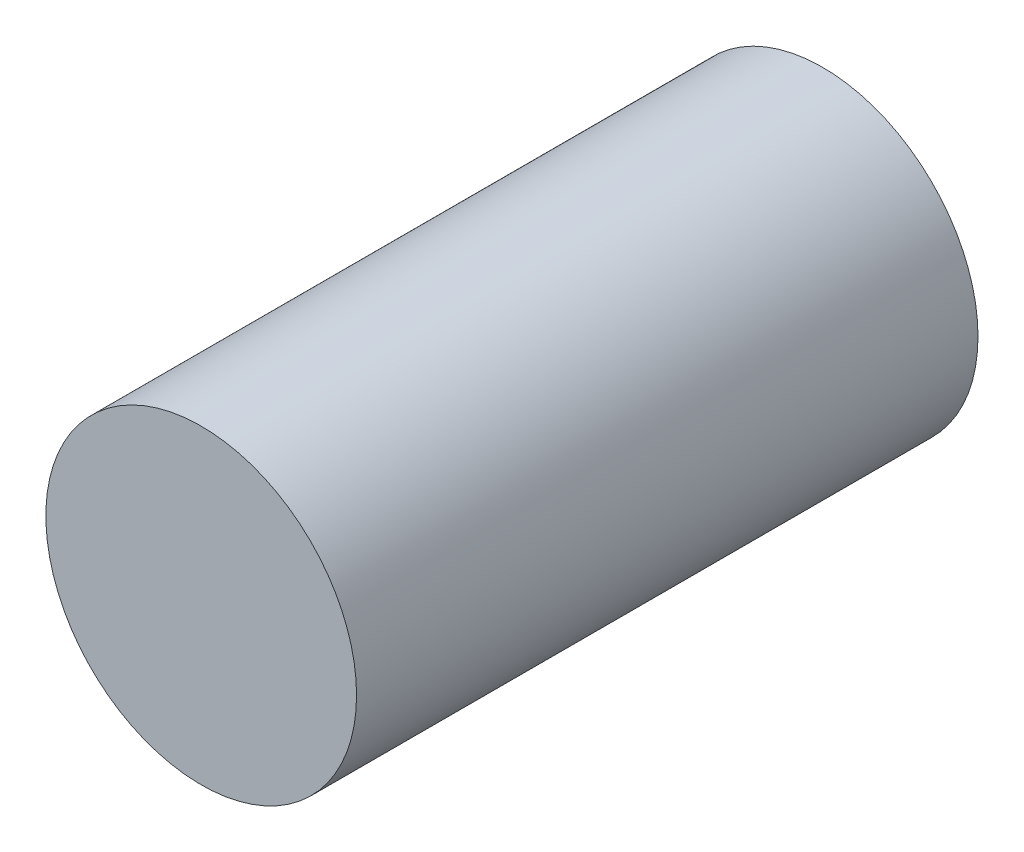
from build123d import *

# Parameters (mm, degrees)
SKETCH1_R           = 20
BOSS_EXTRUDE1_DEPTH = 80


with BuildPart() as part:
    # Sketch1 → Boss-Extrude1 (new body)
    with BuildSketch(Plane.XY):
        Circle(SKETCH1_R)
    extrude(amount=BOSS_EXTRUDE1_DEPTH)


solid = part.part
